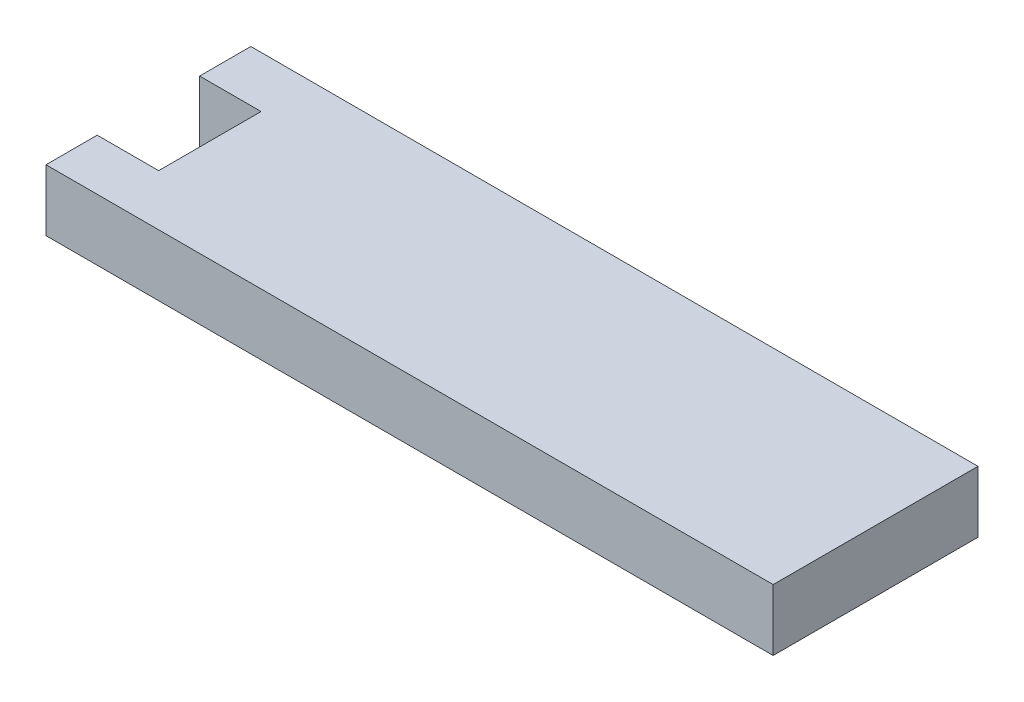
from build123d import *

# Parameters (mm, degrees)
SKETCH1_W           = 71
SKETCH1_H           = 20
BOSS_EXTRUDE1_DEPTH = 6
CUT_EXTRUDE1_DEPTH  = 7


with BuildPart() as part:
    # Sketch1 → Boss-Extrude1 (new body)
    with BuildSketch(Plane(origin=(0, 0, 0), x_dir=(1, 0, 0), z_dir=(0, 1, 0))):
        Rectangle(SKETCH1_W, SKETCH1_H)
    extrude(amount=BOSS_EXTRUDE1_DEPTH)

    # Sketch4 → Cut-Extrude1 (cut, through all)
    with BuildSketch(Plane.XZ):
        Polygon((-35.5, 5), (-29.5, 5), (-29.5, 0), (-29.5, -5), (-35.5, -5), align=None)
    extrude(amount=-CUT_EXTRUDE1_DEPTH, mode=Mode.SUBTRACT)


solid = part.part
